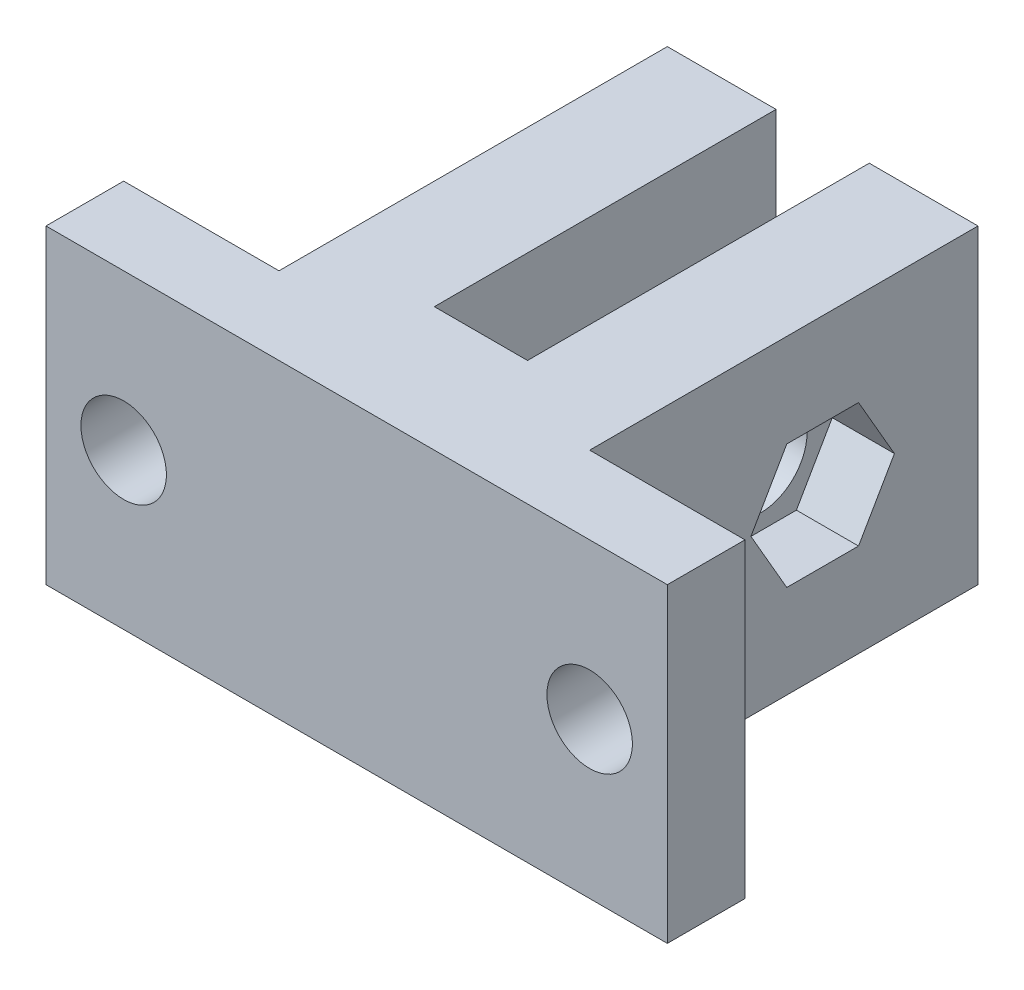
from build123d import *

# Parameters (mm, degrees)
SKETCH1_W           = 40
SKETCH1_H           = 20
BOSS_EXTRUDE1_DEPTH = 30
SKETCH2_R           = 3
CUT_EXTRUDE1_DEPTH  = 41
SKETCH3_W           = 6
SKETCH3_H           = 22
CUT_EXTRUDE2_DEPTH  = 21
SKETCH4_W           = 10
SKETCH4_H           = 20
CUT_EXTRUDE3_DEPTH  = 25
SKETCH5_R           = 2.75
CUT_EXTRUDE4_DEPTH  = 6
CUT_EXTRUDE5_DEPTH  = 4


with BuildPart() as part:
    # Sketch1 → Boss-Extrude1 (new body)
    with BuildSketch(Plane.XY):
        with Locations((20, 10)):
            Rectangle(SKETCH1_W, SKETCH1_H)
    extrude(amount=BOSS_EXTRUDE1_DEPTH)

    # Sketch2 → Cut-Extrude1 (cut, through all)
    with BuildSketch(Plane.ZY):
        with Locations((10, 10)):
            Circle(SKETCH2_R)
    extrude(amount=-CUT_EXTRUDE1_DEPTH, mode=Mode.SUBTRACT)

    # Sketch3 → Cut-Extrude2 (cut, through all)
    with BuildSketch(Plane(origin=(0, 20, 0), x_dir=(1, 0, 0), z_dir=(0, 1, 0))):
        with Locations((20, -11)):
            Rectangle(SKETCH3_W, SKETCH3_H)
    extrude(amount=-CUT_EXTRUDE2_DEPTH, mode=Mode.SUBTRACT)

    # Sketch4 → Cut-Extrude3 (cut)
    with BuildSketch(Plane(origin=(0, 0, 0), x_dir=(-1, 0, 0), z_dir=(0, 0, -1))):
        with Locations((-35, 10)):
            Rectangle(SKETCH4_W, SKETCH4_H)
        with Locations((-5, 10)):
            Rectangle(SKETCH4_W, SKETCH4_H)
    extrude(amount=-CUT_EXTRUDE3_DEPTH, mode=Mode.SUBTRACT)

    # Sketch5 → Cut-Extrude4 (cut, through all)
    with BuildSketch(Plane(origin=(0, 0, 25), x_dir=(-1, 0, 0), z_dir=(0, 0, -1))):
        with Locations((-35, 10)):
            Circle(SKETCH5_R)
        with Locations((-5, 10)):
            Circle(SKETCH5_R)
    extrude(amount=-CUT_EXTRUDE4_DEPTH, mode=Mode.SUBTRACT)

    # Sketch6 → Cut-Extrude5 (cut)
    with BuildSketch(Plane(origin=(30, 0, 0), x_dir=(0, 0, -1), z_dir=(1, 0, 0))):
        Polygon((-7.690598923, 14), (-12.309401077, 14), (-14.618802154, 10), (-12.309401077, 6), (-7.690598923, 6), (-5.381197846, 10), align=None)
    extrude(amount=-CUT_EXTRUDE5_DEPTH, mode=Mode.SUBTRACT)


solid = part.part
